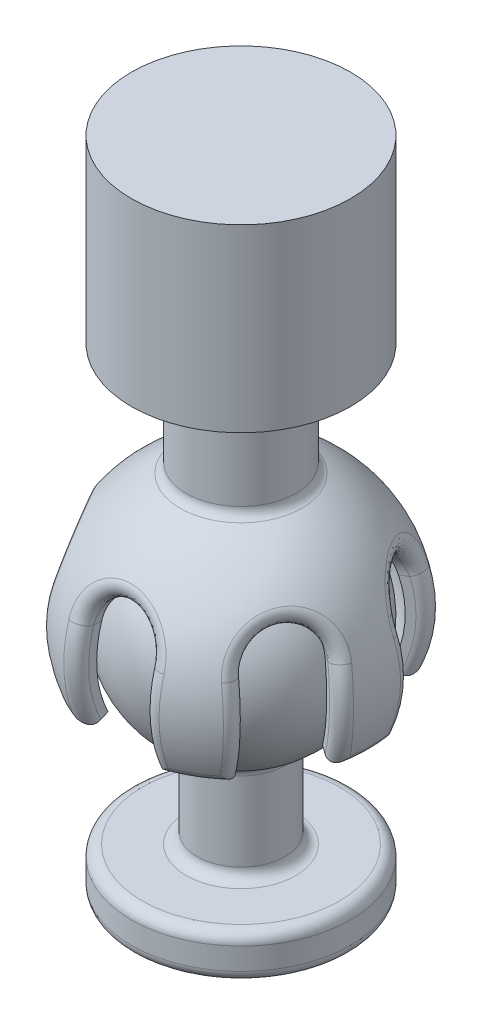
from build123d import *

# Parameters (mm, degrees)
CUT_EXTRUDE1_DEPTH = 7.3
CIRPATTERN1_COUNT  = 6
FILLET1_R          = 0.5


with BuildPart() as part:
    # Sketch2 → Joystick (revolve)
    with BuildSketch(Plane.XY):
        with BuildLine():
            Line((0, -2), (4.5, -2))
            ThreePointArc((4.5, -2), (4.853553391, -1.853553391), (5, -1.5))
            Line((5, -1.5), (5, -0.5))
            ThreePointArc((5, -0.5), (4.853553391, -0.146446609), (4.5, 0))
            Line((4.5, 0), (2.5, 0))
            ThreePointArc((2.5, 0), (2.146446609, 0.146446609), (2, 0.5))
            Line((2, 0.5), (2, 4.101020514))
            ThreePointArc((2, 4.101020514), (2.073598567, 4.362136998), (2.272727273, 4.546382286))
            ThreePointArc((2.272727273, 4.546382286), (4.86148581, 10.168741081), (0, 14))
            Line((0, 14), (0, 11))
            Line((0, 11), (0, -2))
        make_face()
    revolve(axis=Axis((0, 14.75249226, 0), (0, -1, 0)))


with BuildPart() as body_2:
    # Sketch3 → Revolve2 (revolve)
    with BuildSketch(Plane.XY):
        with BuildLine():
            Line((-4.803431271, 6.760123213), (-5.709739058, 6.337504951))
            ThreePointArc((-5.709739058, 6.337504951), (-5.889008635, 11.238208501), (-2.5, 14.782732918))
            Line((-2.5, 14.782732918), (-2.5, 19.782732918))
            Line((-2.5, 19.782732918), (-5, 19.782732918))
            Line((-5, 19.782732918), (-5, 28))
            Line((-5, 28), (0, 28))
            Line((0, 28), (0, 14.3))
            ThreePointArc((0, 14.3), (-4.469974663, 11.847687924), (-4.803431271, 6.760123213))
        make_face()
    revolve(axis=Axis((0, 9, 0), (0, 1, 0)))

    # Sketch4 → Cut-Extrude1 (cut, symmetric)
    with BuildSketch(Plane.XY):
        with BuildLine():
            Line((1.5, 10.5), (1.5, 4.5))
            ThreePointArc((1.5, 4.5), (0, 3), (-1.5, 4.5))
            Line((-1.5, 4.5), (-1.5, 10.5))
            ThreePointArc((-1.5, 10.5), (0, 12), (1.5, 10.5))
        make_face()
    cut_extrude1 = extrude(amount=CUT_EXTRUDE1_DEPTH, both=True, mode=Mode.SUBTRACT)

    # CirPattern1: Cut-Extrude1 ×6 about axis
    cirpattern1_axis = Axis((0, 0, 0), (0, 1, 0))
    for i in range(1, CIRPATTERN1_COUNT):
        add(cut_extrude1.rotate(cirpattern1_axis, i * 360 / CIRPATTERN1_COUNT), mode=Mode.SUBTRACT)

    # Fillet1
    fillet1_edges = [body_2.edges().sort_by_distance(p)[0] for p in [
        (-2.854869529, 6.337504951, 4.944779073),
        (2.854869529, 6.337504951, -4.944779073),
        (0, 12, 5.539855594),
        (0, 12, -5.539855594),
        (1.5, 8.381480539, -6.087481719),
        (1.5, 8.381480539, 6.087481719),
        (-1.5, 8.381480539, -6.087481719),
        (-1.5, 8.381480539, 6.087481719),
        (-5.662381453, 6.337504951, 0.733864015),
        (-2.854869529, 6.337504951, -4.944779073),
        (5.709739058, 6.337504951, 0),
        (2.854869529, 6.337504951, 4.944779073),
        (-4.521913814, 8.381480539, -4.342778965),
        (-4.797655677, 12, -2.769927797),
        (-6.021913814, 8.381480539, -1.744702754),
        (-6.021913814, 8.381480539, 1.744702754),
        (-4.797655678, 12, 2.769927797),
        (-4.521913814, 8.381480539, 4.342778965),
        (4.521913814, 8.381480539, 4.342778965),
        (4.797655678, 12, 2.769927797),
        (6.021913814, 8.381480539, 1.744702754),
        (2.5, 14.782732918, 0),
        (6.021913814, 8.381480539, -1.744702754),
        (4.797655677, 12, -2.769927797),
        (4.521913814, 8.381480539, -4.342778965),
    ]]
    fillet(fillet1_edges, radius=FILLET1_R)


solid = Compound([part.part, body_2.part])
